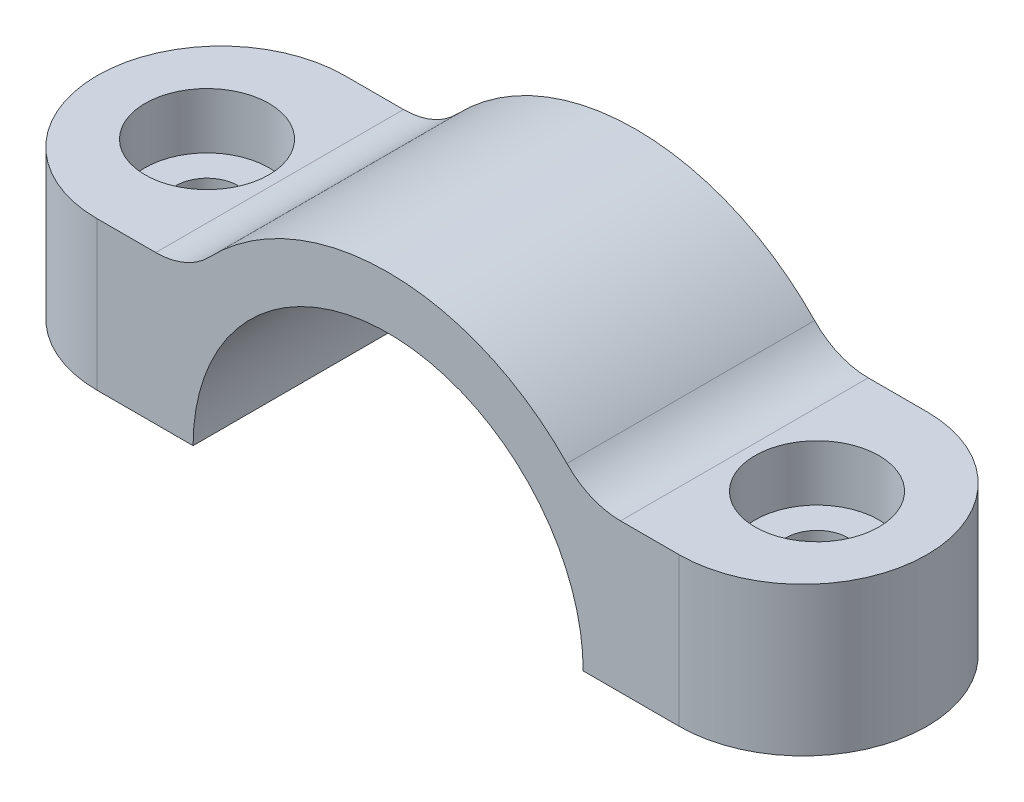
from build123d import *

# Parameters (mm, degrees)
BOSS_EXTRUDE1_DEPTH = 12.7
FILLET1_R           = 7.62
FILLET2_R           = 7.62
SKETCH2_R           = 3.175
CUT_EXTRUDE1_DEPTH  = 9.525
SKETCH3_R           = 6.35
CUT_EXTRUDE2_DEPTH  = 5.715
SKETCH4_OUTSIDE_W   = 105.562
SKETCH4_OUTSIDE_H   = 45.872
CUT_EXTRUDE3_DEPTH  = 26.4


with BuildPart() as part:
    # Sketch1 → Boss-Extrude1 (new body, symmetric)
    with BuildSketch(Plane.XY):
        with BuildLine():
            Line((-42.545, 0), (-42.545, 15.24))
            Line((-42.545, 15.24), (-20.32, 15.24))
            ThreePointArc((-20.32, 15.24), (0, 25.4), (20.32, 15.24))
            Line((20.32, 15.24), (42.545, 15.24))
            Line((42.545, 15.24), (42.545, 0))
            Line((42.545, 0), (20, 0))
            ThreePointArc((20, 0), (0, 20), (-20, 0))
            Line((-20, 0), (-42.545, 0))
        make_face()
    extrude(amount=BOSS_EXTRUDE1_DEPTH, both=True)

    # Fillet1
    fillet1_edges = [part.edges().sort_by_distance(p)[0] for p in [
        (20.32, 15.24, 0),
    ]]
    fillet(fillet1_edges, radius=FILLET1_R)

    # Fillet2
    fillet2_edges = [part.edges().sort_by_distance(p)[0] for p in [
        (-20.32, 15.24, 0),
    ]]
    fillet(fillet2_edges, radius=FILLET2_R)

    # Sketch2 → Cut-Extrude1 (cut)
    with BuildSketch(Plane.XZ):
        with Locations((-31.2725, 0)):
            Circle(SKETCH2_R)
    cut_extrude1 = extrude(amount=-CUT_EXTRUDE1_DEPTH, mode=Mode.SUBTRACT)

    # Sketch3 → Cut-Extrude2 (cut)
    with BuildSketch(Plane.XZ.offset(-9.525)):
        with Locations((-31.2725, 0)):
            Circle(SKETCH3_R)
    cut_extrude2 = extrude(amount=-CUT_EXTRUDE2_DEPTH, mode=Mode.SUBTRACT)

    # Mirror1: Cut-Extrude1, Cut-Extrude2 across plane
    add(cut_extrude1.mirror(Plane(origin=(0, 0, 0), x_dir=(0, 0, 1), z_dir=(1, 0, 0))), mode=Mode.SUBTRACT)
    add(cut_extrude2.mirror(Plane(origin=(0, 0, 0), x_dir=(0, 0, 1), z_dir=(1, 0, 0))), mode=Mode.SUBTRACT)

    # Sketch4 outside → Cut-Extrude3 (cut, through all)
    with BuildSketch(Plane(origin=(0, 0, 0), x_dir=(1, 0, 0), z_dir=(0, 1, 0))):
        Rectangle(SKETCH4_OUTSIDE_W, SKETCH4_OUTSIDE_H)
        with BuildLine():
            Line((-29.845, -12.7), (29.845, -12.7))
            ThreePointArc((29.845, -12.7), (42.545, 0), (29.845, 12.7))
            Line((29.845, 12.7), (-29.845, 12.7))
            ThreePointArc((-29.845, 12.7), (-42.545, 0), (-29.845, -12.7))
        make_face(mode=Mode.SUBTRACT)
    extrude(amount=CUT_EXTRUDE3_DEPTH, mode=Mode.SUBTRACT)


solid = part.part
